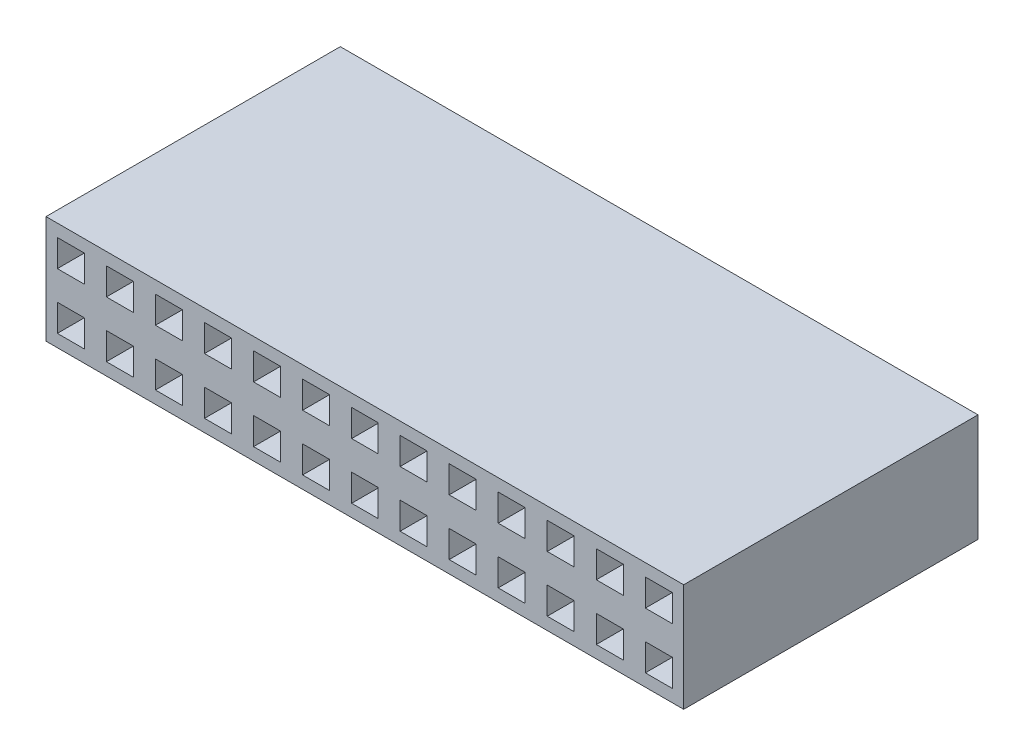
from build123d import *

# Parameters (mm, degrees)
SKETCH1_W           = 33.02
SKETCH1_H           = 5.588
SKETCH1_W_2         = 1.397
SKETCH1_H_2         = 1.397
SKETCH1_W_3         = 1.364533422
BOSS_EXTRUDE1_DEPTH = 15.24


with BuildPart() as part:
    # Sketch1 → Boss-Extrude1 (new body)
    with BuildSketch(Plane.XY):
        Rectangle(SKETCH1_W, SKETCH1_H)
        with Locations((2.523766711, -1.451626982)):
            Rectangle(SKETCH1_W_2, SKETCH1_H_2, mode=Mode.SUBTRACT)
        with Locations((0, -1.451626982)):
            Rectangle(SKETCH1_W_3, SKETCH1_H_2, mode=Mode.SUBTRACT)
        with Locations((5.063766711, -1.451626982)):
            Rectangle(SKETCH1_W_2, SKETCH1_H_2, mode=Mode.SUBTRACT)
        with Locations((7.603766711, -1.451626982)):
            Rectangle(SKETCH1_W_2, SKETCH1_H_2, mode=Mode.SUBTRACT)
        with Locations((10.143766711, -1.451626982)):
            Rectangle(SKETCH1_W_2, SKETCH1_H_2, mode=Mode.SUBTRACT)
        with Locations((12.683766711, -1.451626982)):
            Rectangle(SKETCH1_W_2, SKETCH1_H_2, mode=Mode.SUBTRACT)
        with Locations((15.223766711, -1.451626982)):
            Rectangle(SKETCH1_W_2, SKETCH1_H_2, mode=Mode.SUBTRACT)
        with Locations((-15.223766711, -1.451626982)):
            Rectangle(SKETCH1_W_2, SKETCH1_H_2, mode=Mode.SUBTRACT)
        with Locations((-12.683766711, -1.451626982)):
            Rectangle(SKETCH1_W_2, SKETCH1_H_2, mode=Mode.SUBTRACT)
        with Locations((-10.143766711, -1.451626982)):
            Rectangle(SKETCH1_W_2, SKETCH1_H_2, mode=Mode.SUBTRACT)
        with Locations((-7.603766711, -1.451626982)):
            Rectangle(SKETCH1_W_2, SKETCH1_H_2, mode=Mode.SUBTRACT)
        with Locations((-5.063766711, -1.451626982)):
            Rectangle(SKETCH1_W_2, SKETCH1_H_2, mode=Mode.SUBTRACT)
        with Locations((-2.523766711, -1.451626982)):
            Rectangle(SKETCH1_W_2, SKETCH1_H_2, mode=Mode.SUBTRACT)
        with Locations((-2.523766711, 1.451626982)):
            Rectangle(SKETCH1_W_2, SKETCH1_H_2, mode=Mode.SUBTRACT)
        with Locations((0, 1.451626982)):
            Rectangle(SKETCH1_W_3, SKETCH1_H_2, mode=Mode.SUBTRACT)
        with Locations((-5.063766711, 1.451626982)):
            Rectangle(SKETCH1_W_2, SKETCH1_H_2, mode=Mode.SUBTRACT)
        with Locations((-7.603766711, 1.451626982)):
            Rectangle(SKETCH1_W_2, SKETCH1_H_2, mode=Mode.SUBTRACT)
        with Locations((-10.143766711, 1.451626982)):
            Rectangle(SKETCH1_W_2, SKETCH1_H_2, mode=Mode.SUBTRACT)
        with Locations((-12.683766711, 1.451626982)):
            Rectangle(SKETCH1_W_2, SKETCH1_H_2, mode=Mode.SUBTRACT)
        with Locations((-15.223766711, 1.451626982)):
            Rectangle(SKETCH1_W_2, SKETCH1_H_2, mode=Mode.SUBTRACT)
        with Locations((15.223766711, 1.451626982)):
            Rectangle(SKETCH1_W_2, SKETCH1_H_2, mode=Mode.SUBTRACT)
        with Locations((12.683766711, 1.451626982)):
            Rectangle(SKETCH1_W_2, SKETCH1_H_2, mode=Mode.SUBTRACT)
        with Locations((10.143766711, 1.451626982)):
            Rectangle(SKETCH1_W_2, SKETCH1_H_2, mode=Mode.SUBTRACT)
        with Locations((7.603766711, 1.451626982)):
            Rectangle(SKETCH1_W_2, SKETCH1_H_2, mode=Mode.SUBTRACT)
        with Locations((5.063766711, 1.451626982)):
            Rectangle(SKETCH1_W_2, SKETCH1_H_2, mode=Mode.SUBTRACT)
        with Locations((2.523766711, 1.451626982)):
            Rectangle(SKETCH1_W_2, SKETCH1_H_2, mode=Mode.SUBTRACT)
    extrude(amount=BOSS_EXTRUDE1_DEPTH)


solid = part.part
